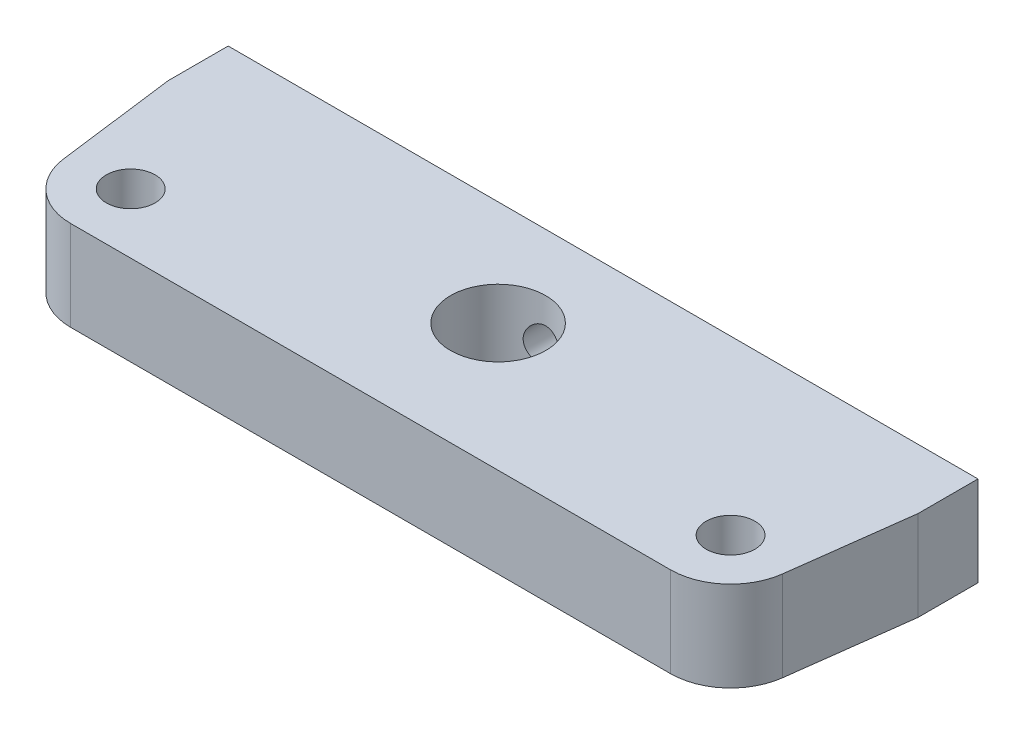
from build123d import *

# Parameters (mm, degrees)
SKETCH1_R           = 14
SKETCH1_R_2         = 5
BOSS_EXTRUDE1_DEPTH = 38
SKETCH2_R           = 6.35
SKETCH2_R_2         = 3.25
BOSS_EXTRUDE2_DEPTH = 12
SKETCH3_R           = 2.5
CUT_EXTRUDE6_DEPTH  = 10


with BuildPart() as part:
    # Sketch1 → Boss-Extrude1 (new body)
    with BuildSketch(Plane(origin=(0, 0, 0), x_dir=(1, 0, 0), z_dir=(0, 1, 0))):
        with BuildLine():
            Line((40, 57), (-40, 57))
            ThreePointArc((-40, 57), (-58.987886037, 46.111263827), (-59.17994648, 24.223653075))
            Line((-59.17994648, 24.223653075), (-47.255332989, 3))
            Line((-47.255332989, 3), (-32.311027529, 3))
            ThreePointArc((-32.311027529, 3), (32.415238263, -1.501608583), (-32.45, 0))
            Line((-32.45, 0), (-47.255332989, 0))
            Line((-47.255332989, 0), (-47.255332989, -10))
            Line((-47.255332989, -10), (-41.255332989, -10))
            ThreePointArc((-41.255332989, -10), (-4.643586709, -42.195255687), (38.093342034, -18.732319468))
            Line((38.093342034, -18.732319468), (59.742132503, 25.291848568))
            ThreePointArc((59.742132503, 25.291848568), (58.675911377, 46.627997861), (40, 57))
        make_face()
        with Locations((-40, 35)):
            Circle(SKETCH1_R, mode=Mode.SUBTRACT)
        with Locations((0, 44)):
            Circle(SKETCH1_R_2, mode=Mode.SUBTRACT)
        with Locations((40, 35)):
            Circle(SKETCH1_R, mode=Mode.SUBTRACT)
    extrude(amount=BOSS_EXTRUDE1_DEPTH)


with BuildPart() as body_2:
    # Sketch2 → Boss-Extrude2 (new body)
    with BuildSketch(Plane(origin=(0, 38, 0), x_dir=(1, 0, 0), z_dir=(0, 1, 0))):
        with BuildLine():
            Line((-40, 27), (40, 27))
            ThreePointArc((40, 27), (45.282843577, 28.992374534), (47.934336402, 33.977109066))
            Line((47.934336402, 33.977109066), (50, 50))
            Line((50, 50), (50, 58))
            Line((50, 58), (-50, 58))
            Line((-50, 58), (-50, 50))
            Line((-50, 50), (-47.934336402, 33.977109066))
            ThreePointArc((-47.934336402, 33.977109066), (-45.282843577, 28.992374534), (-40, 27))
        make_face()
        with Locations((0, 44)):
            Circle(SKETCH2_R, mode=Mode.SUBTRACT)
        with Locations((-40, 35)):
            Circle(SKETCH2_R_2, mode=Mode.SUBTRACT)
        with Locations((40, 35)):
            Circle(SKETCH2_R_2, mode=Mode.SUBTRACT)
    extrude(amount=BOSS_EXTRUDE2_DEPTH)

    # Sketch3 → Cut-Extrude6 (cut)
    with BuildSketch(Plane(origin=(0, 0, -58), x_dir=(-1, 0, 0), z_dir=(0, 0, -1))):
        with Locations((0, 44)):
            Circle(SKETCH3_R)
        with Locations((40, 44)):
            Circle(SKETCH3_R)
        with Locations((-40, 44)):
            Circle(SKETCH3_R)
    extrude(amount=-CUT_EXTRUDE6_DEPTH, mode=Mode.SUBTRACT)


solid = body_2.part
